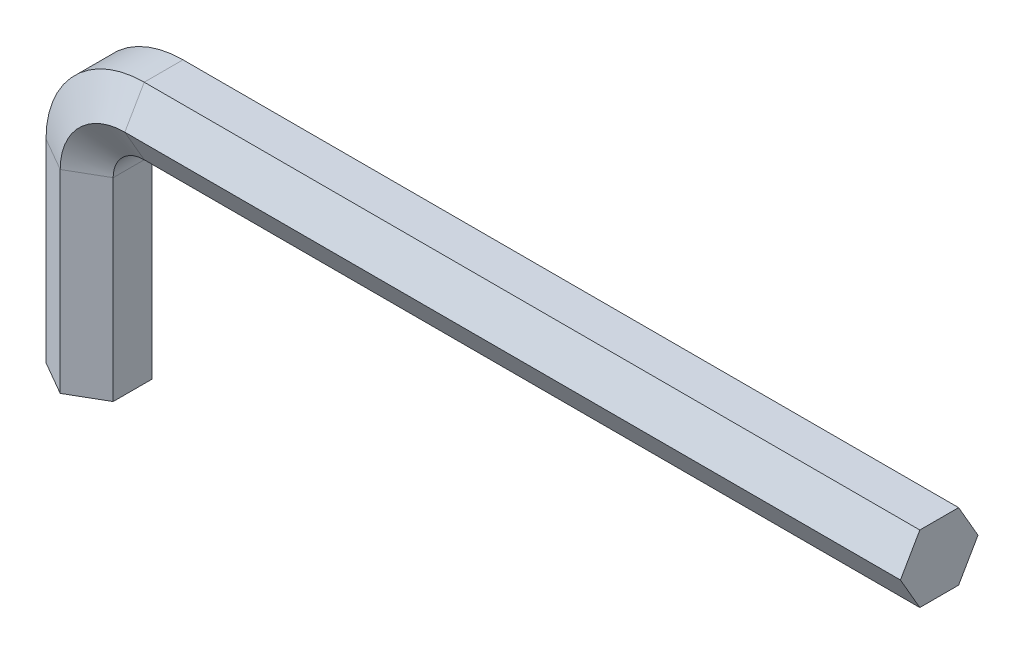
from build123d import *


with BuildPart() as part:
    # Sweep1: sweep along a path in Sketch1
    with BuildLine(Plane.XY) as sweep1_path:
        Line((0, 0), (0, 15))
        ThreePointArc((0, 15), (1.464466094, 18.535533906), (5, 20))
        Line((5, 20), (65, 20))
    # Sketch2 → Sweep1 (sweep)
    with BuildSketch(Plane(origin=(65, 20, 0), x_dir=(0, 0, -1), z_dir=(1, 0, 0))):
        Polygon((3, 0), (1.5, 2.598076211), (-1.5, 2.598076211), (-3, 0), (-1.5, -2.598076211), (1.5, -2.598076211), align=None)
    sweep(path=sweep1_path.line)


solid = part.part
